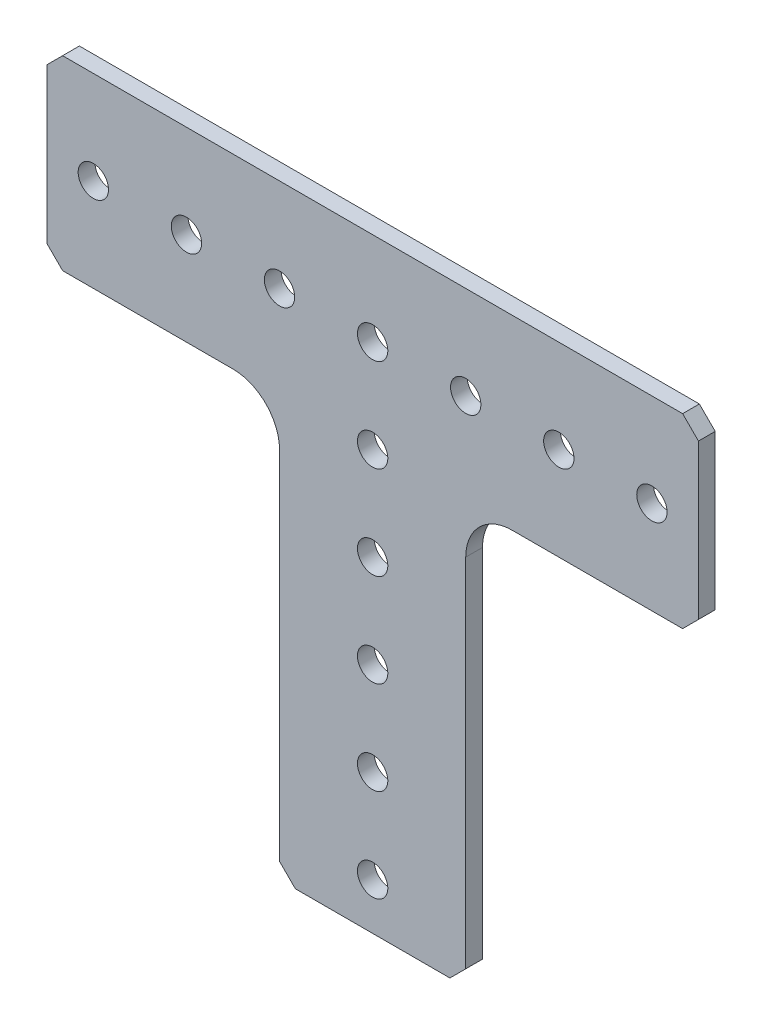
from build123d import *

# Parameters (mm, degrees)
SKETCH1_R           = 2.0701
BOSS_EXTRUDE1_DEPTH = 2.286


with BuildPart() as part:
    # Sketch1 → Boss-Extrude1 (new body)
    with BuildSketch(Plane.XY.offset(2.286)):
        with BuildLine():
            Line((12.7, -54.991), (12.7, -6.35))
            ThreePointArc((12.7, -6.35), (14.559871939, -1.859871939), (19.05, 0))
            Line((19.05, 0), (42.291, 0))
            Line((42.291, 0), (44.45, 2.159))
            Line((44.45, 2.159), (44.45, 23.241))
            Line((44.45, 23.241), (42.291, 25.4))
            Line((42.291, 25.4), (-42.291, 25.4))
            Line((-42.291, 25.4), (-44.45, 23.241))
            Line((-44.45, 23.241), (-44.45, 2.159))
            Line((-44.45, 2.159), (-42.291, 0))
            Line((-42.291, 0), (-19.05, 0))
            ThreePointArc((-19.05, 0), (-14.559871939, -1.859871939), (-12.7, -6.35))
            Line((-12.7, -6.35), (-12.7, -54.991))
            Line((-12.7, -54.991), (-10.541, -57.15))
            Line((-10.541, -57.15), (10.541, -57.15))
            Line((10.541, -57.15), (12.7, -54.991))
        make_face()
        with Locations((0, -38.1)):
            Circle(SKETCH1_R, mode=Mode.SUBTRACT)
        with Locations((0, -12.7)):
            Circle(SKETCH1_R, mode=Mode.SUBTRACT)
        with Locations((38.1, 12.7)):
            Circle(SKETCH1_R, mode=Mode.SUBTRACT)
        with Locations((12.7, 12.7)):
            Circle(SKETCH1_R, mode=Mode.SUBTRACT)
        with Locations((-12.7, 12.7)):
            Circle(SKETCH1_R, mode=Mode.SUBTRACT)
        with Locations((-38.1, 12.7)):
            Circle(SKETCH1_R, mode=Mode.SUBTRACT)
        with Locations((-25.4, 12.7)):
            Circle(SKETCH1_R, mode=Mode.SUBTRACT)
        with Locations((0, 12.7)):
            Circle(SKETCH1_R, mode=Mode.SUBTRACT)
        with Locations((25.4, 12.7)):
            Circle(SKETCH1_R, mode=Mode.SUBTRACT)
        Circle(SKETCH1_R, mode=Mode.SUBTRACT)
        with Locations((0, -25.4)):
            Circle(SKETCH1_R, mode=Mode.SUBTRACT)
        with Locations((0, -50.8)):
            Circle(SKETCH1_R, mode=Mode.SUBTRACT)
    extrude(amount=-BOSS_EXTRUDE1_DEPTH)


solid = part.part
